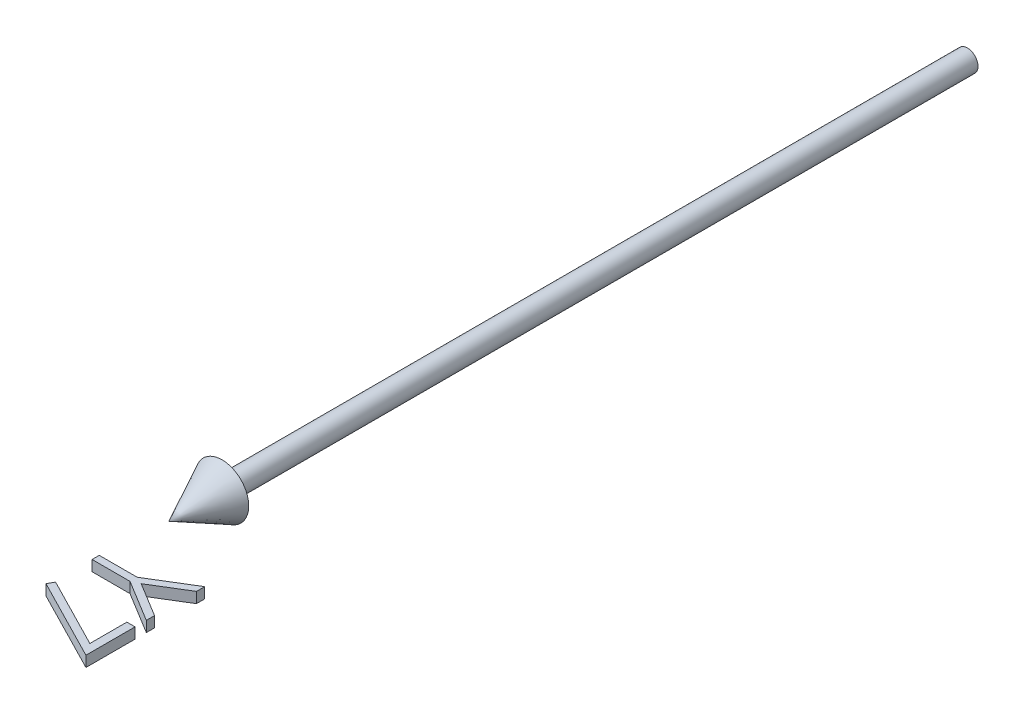
from build123d import *

# Parameters (mm, degrees)
BOSS_EXTRUDE1_DEPTH        = 1
BOSS_EXTRUDE1_DEPTH_BACK   = 1
BOSS_EXTRUDE1_2_DEPTH      = 1
BOSS_EXTRUDE1_2_DEPTH_BACK = 1


with BuildPart() as part:
    # Sketch2 → Revolve1 (revolve)
    with BuildSketch(Plane(origin=(0, 0, 0), x_dir=(1, 0, 0), z_dir=(0, 1, 0))):
        Polygon((0, -150), (5, -140), (2, -140), (2, 0), (0, 0), align=None)
    revolve(axis=Axis((0, 0, -41.949952025), (0, 0, 1)))


with BuildPart() as body_2:
    # Sketch3 → Boss-Extrude1 (new, two sides: drawn at the far end of the back side and taken through both)
    with BuildSketch(Plane(origin=(0, 0, 0), x_dir=(1, 0, 0), z_dir=(0, 1, 0)).offset(-BOSS_EXTRUDE1_DEPTH_BACK)):
        Polygon((15, -158.269230769), (15, -159.810697115), (8.5546875, -163.753004808), (15, -167.689302885), (15, -169.230769231), (7.130408654, -164.423076923), (0, -164.423076923), (0, -163.076923077), (7.130408654, -163.076923077), align=None)
    extrude(amount=BOSS_EXTRUDE1_DEPTH + BOSS_EXTRUDE1_DEPTH_BACK)


with BuildPart() as body_3:
    # Sketch3 → Boss-Extrude1 2 (new, two sides: drawn at the far end of the back side and taken through both)
    with BuildSketch(Plane(origin=(0, 0, 0), x_dir=(1, 0, 0), z_dir=(0, 1, 0)).offset(-BOSS_EXTRUDE1_2_DEPTH_BACK)):
        Polygon((15, -171.346153846), (15, -180.576923077), (-0.384615385, -172.692307692), (0.255408654, -171.529447115), (13.461538462, -178.299278846), (13.461538462, -171.346153846), align=None)
    extrude(amount=BOSS_EXTRUDE1_2_DEPTH + BOSS_EXTRUDE1_2_DEPTH_BACK)


solid = Compound([part.part, body_2.part, body_3.part])
